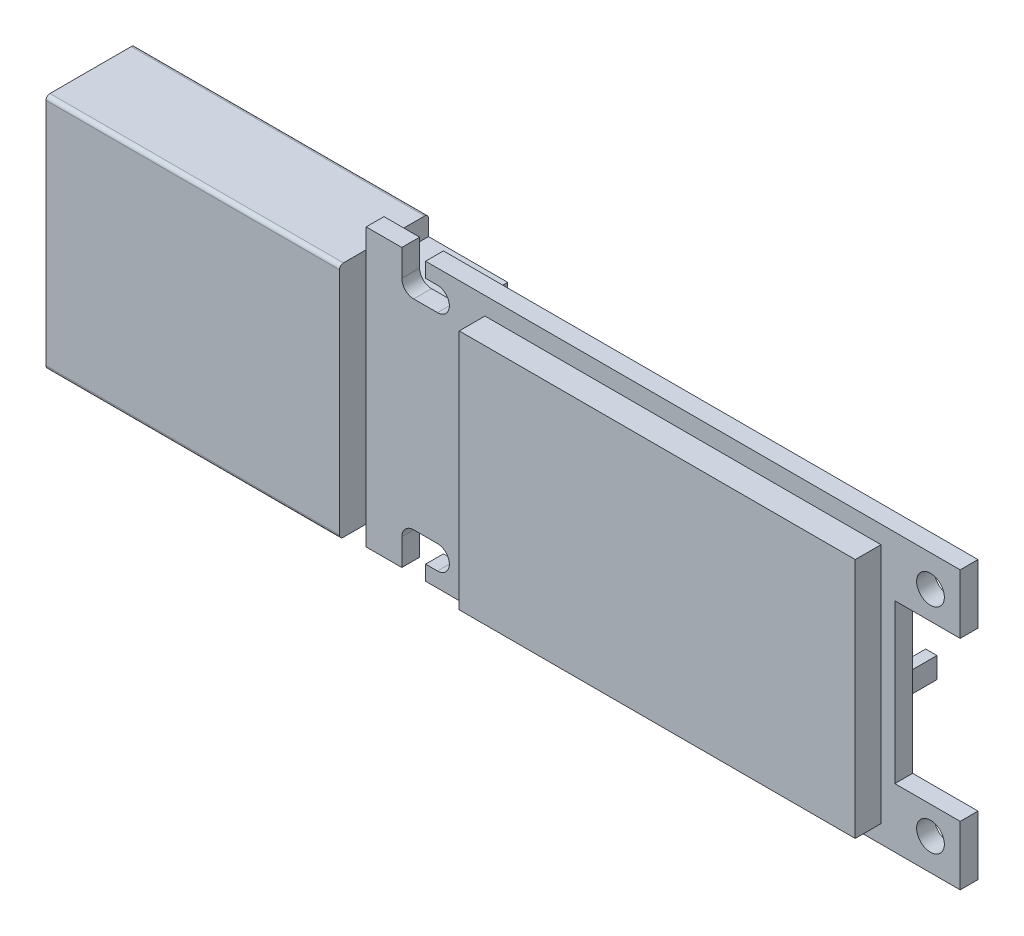
from build123d import *

# Parameters (mm, degrees)
ESQUISSE1_W             = 14.82
ESQUISSE1_H             = 12
BOSS_EXTRU_1_DEPTH      = 4.5
ESQUISSE2_W             = 2
ESQUISSE2_H             = 11.4
ENL_V_MAT_EXTRU_1_DEPTH = 9
CONG_1_R                = 0.2
ESQUISSE3_W             = 30
ESQUISSE3_H             = 14
BOSS_EXTRU_2_DEPTH      = 0.9
ENL_V_MAT_EXTRU_2_REACH = 6.5
ESQUISSE4_W             = 2
ESQUISSE4_H             = 2.5
ESQUISSE5_R             = 0.7
ESQUISSE5_W             = 3.3
ESQUISSE5_H             = 8
ENL_V_MAT_EXTRU_3_DEPTH = 4.15
ESQUISSE6_W             = 20
ESQUISSE6_H             = 12.2
BOSS_EXTRU_3_DEPTH      = 1.3
ESQUISSE7_W             = 8.197434371
ESQUISSE7_H             = 6.831195309
ESQUISSE7_W_2           = 1.366239062
ESQUISSE7_H_2           = 2.101906249
ESQUISSE7_W_3           = 1.261143749
ESQUISSE7_W_4           = 2.522287499
ESQUISSE7_H_3           = 1.050953124
ESQUISSE7_W_5           = 0.570374351
ESQUISSE7_H_4           = 1.05519255
BOSS_EXTRU_4_DEPTH      = 1.4
ESQUISSE8_W             = 4
ESQUISSE8_H             = 10
BOSS_EXTRU_5_DEPTH      = 2.25
ESQUISSE9_W             = 1.2
ESQUISSE9_H             = 1.35
ENL_V_MAT_EXTRU_4_DEPTH = 4.15


with BuildPart() as part:
    # Esquisse1 → Boss.-Extru.1 (new body)
    with BuildSketch(Plane.XY):
        Rectangle(ESQUISSE1_W, ESQUISSE1_H)
    extrude(amount=BOSS_EXTRU_1_DEPTH)

    # Esquisse2 → Enlèv. mat.-Extru.1 (cut)
    with BuildSketch(Plane.ZY.offset(7.41)):
        with Locations((1.3, 0)):
            Rectangle(ESQUISSE2_W, ESQUISSE2_H)
    extrude(amount=-ENL_V_MAT_EXTRU_1_DEPTH, mode=Mode.SUBTRACT)

    # Congé1
    cong_1_edges = [part.edges().sort_by_distance(p)[0] for p in [
        (0, -6, 4.5),
        (0, -6, 0),
        (0, 6, 0),
        (0, 6, 4.5),
    ]]
    fillet(cong_1_edges, radius=CONG_1_R)

    # Esquisse3 → Boss.-Extru.2 (add)
    with BuildSketch(Plane.XY.offset(2.25)):
        with Locations((22.41, 0)):
            Rectangle(ESQUISSE3_W, ESQUISSE3_H)
    extrude(amount=BOSS_EXTRU_2_DEPTH)

    # Esquisse4 → Enlèv. mat.-Extru.2 (cut, up to next)
    with BuildSketch(Plane(origin=(0, 0, 0), x_dir=(-1, 0, 0), z_dir=(0, 0, -1)), mode=Mode.PRIVATE) as enl_v_mat_extru_2_sk1:
        with Locations((1.41, 2.95)):
            Rectangle(ESQUISSE4_W, ESQUISSE4_H)
    enl_v_mat_extru_2_tool1 = extrude(enl_v_mat_extru_2_sk1.sketch, amount=-ENL_V_MAT_EXTRU_2_REACH, mode=Mode.PRIVATE) & part.part
    add(enl_v_mat_extru_2_tool1.solids().sort_by_distance((-1.41, 2.95, 0))[0], mode=Mode.SUBTRACT)
    # Esquisse4 → Enlèv. mat.-Extru.2 (cut, up to next)
    with BuildSketch(Plane(origin=(0, 0, 0), x_dir=(-1, 0, 0), z_dir=(0, 0, -1)), mode=Mode.PRIVATE) as enl_v_mat_extru_2_sk2:
        with Locations((1.41, -2.95)):
            Rectangle(ESQUISSE4_W, ESQUISSE4_H)
    enl_v_mat_extru_2_tool2 = extrude(enl_v_mat_extru_2_sk2.sketch, amount=-ENL_V_MAT_EXTRU_2_REACH, mode=Mode.PRIVATE) & part.part
    add(enl_v_mat_extru_2_tool2.solids().sort_by_distance((-1.41, -2.95, 0))[0], mode=Mode.SUBTRACT)

    # Esquisse5 → Enlèv. mat.-Extru.3 (cut, through all)
    with BuildSketch(Plane.XY.offset(3.15)):
        with Locations((35.91, 5.4)):
            Circle(ESQUISSE5_R)
        with Locations((35.91, -5.4)):
            Circle(ESQUISSE5_R)
        with Locations((35.76, 0)):
            Rectangle(ESQUISSE5_W, ESQUISSE5_H)
        with BuildLine():
            Line((9.81, 6.25), (11.01, 6.25))
            ThreePointArc((11.01, 6.25), (11.61, 5.65), (11.01, 5.05))
            Line((11.01, 5.05), (9.81, 5.05))
            ThreePointArc((9.81, 5.05), (9.21, 5.65), (9.81, 6.25))
        make_face()
        with BuildLine():
            Line((9.81, -6.25), (11.01, -6.25))
            ThreePointArc((11.01, -6.25), (11.61, -5.65), (11.01, -5.05))
            Line((11.01, -5.05), (9.81, -5.05))
            ThreePointArc((9.81, -5.05), (9.21, -5.65), (9.81, -6.25))
        make_face()
    extrude(amount=-ENL_V_MAT_EXTRU_3_DEPTH, mode=Mode.SUBTRACT)

    # Esquisse6 → Boss.-Extru.3 (add)
    with BuildSketch(Plane.XY.offset(3.15)):
        with Locations((23.41, 0)):
            Rectangle(ESQUISSE6_W, ESQUISSE6_H)
    extrude(amount=BOSS_EXTRU_3_DEPTH)

    # Esquisse7 → Boss.-Extru.4 (add)
    with BuildSketch(Plane(origin=(0, 0, 2.25), x_dir=(-1, 0, 0), z_dir=(0, 0, -1))):
        with Locations((-26.770674994, -0.052547657)):
            Rectangle(ESQUISSE7_W, ESQUISSE7_H)
        with Locations((-17.78502578, -3.257954686)):
            Rectangle(ESQUISSE7_W_2, ESQUISSE7_H_2)
        with Locations((-14.684714062, -3.257954686)):
            Rectangle(ESQUISSE7_W_3, ESQUISSE7_H_2)
        with Locations((-18.363049999, 2.837573436)):
            Rectangle(ESQUISSE7_W_4, ESQUISSE7_H_3)
        with Locations((-33.651427146, -0.16121887)):
            Rectangle(ESQUISSE7_W_5, ESQUISSE7_H_4)
    extrude(amount=BOSS_EXTRU_4_DEPTH)

    # Esquisse8 → Boss.-Extru.5 (add)
    with BuildSketch(Plane(origin=(0, 0, 2.25), x_dir=(-1, 0, 0), z_dir=(0, 0, -1))):
        with Locations((-9.41, 0)):
            Rectangle(ESQUISSE8_W, ESQUISSE8_H)
    extrude(amount=BOSS_EXTRU_5_DEPTH)

    # Esquisse9 → Enlèv. mat.-Extru.4 (cut, through all)
    with BuildSketch(Plane.XY.offset(3.15)):
        with Locations((9.81, 6.325)):
            Rectangle(ESQUISSE9_W, ESQUISSE9_H)
        with Locations((9.81, -6.325)):
            Rectangle(ESQUISSE9_W, ESQUISSE9_H)
    extrude(amount=-ENL_V_MAT_EXTRU_4_DEPTH, mode=Mode.SUBTRACT)


solid = part.part
